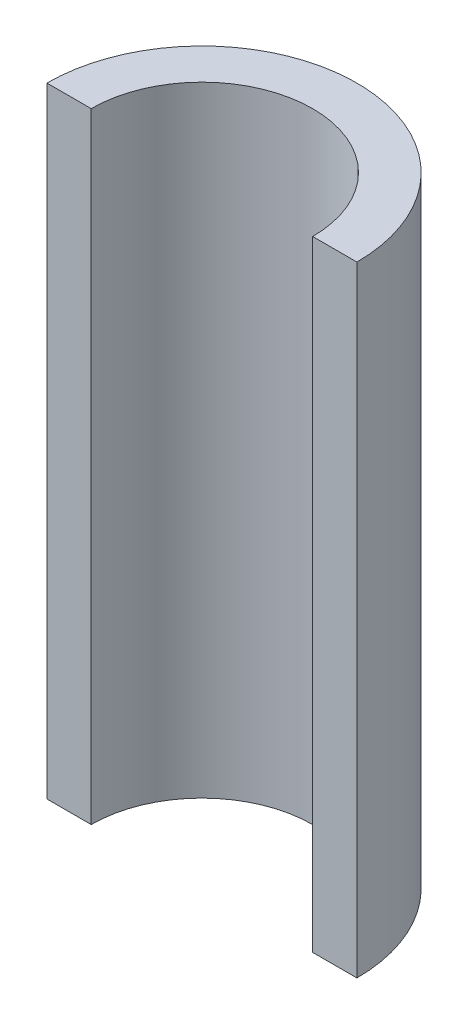
from build123d import *

# Parameters (mm, degrees)
BOSS_EXTRUDE1_DEPTH = 70


with BuildPart() as part:
    # Sketch1 → Boss-Extrude1 (new body)
    with BuildSketch(Plane(origin=(0, 0, 0), x_dir=(1, 0, 0), z_dir=(0, 1, 0))):
        with BuildLine():
            Line((-17.5, 0), (-12.5, 0))
            ThreePointArc((-12.5, 0), (0, 12.5), (12.5, 0))
            Line((12.5, 0), (17.5, 0))
            ThreePointArc((17.5, 0), (0, 17.5), (-17.5, 0))
        make_face()
    extrude(amount=BOSS_EXTRUDE1_DEPTH)


solid = part.part
